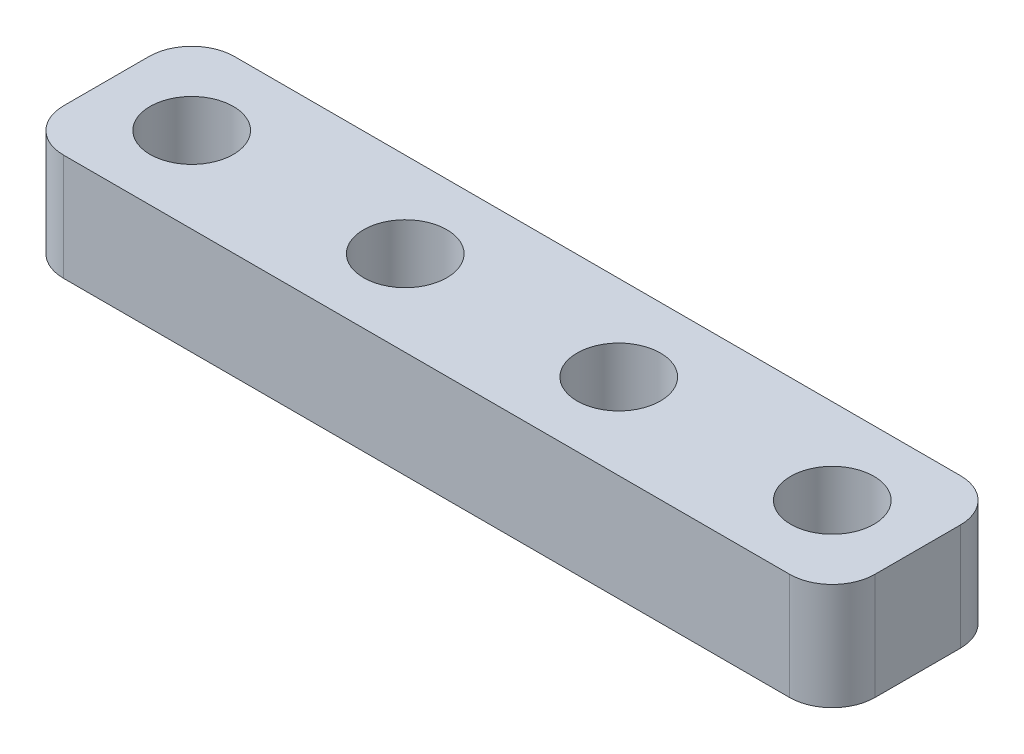
from build123d import *

# Parameters (mm, degrees)
BOSS_EXTRUDE1_DEPTH = 5
SKETCH2_R           = 1.95
CUT_EXTRUDE1_DEPTH  = 6


with BuildPart() as part:
    # Sketch1 → Boss-Extrude1 (new body)
    with BuildSketch(Plane(origin=(0, 0, 0), x_dir=(1, 0, 0), z_dir=(0, 1, 0))):
        with BuildLine():
            Line((2, 0), (36, 0))
            ThreePointArc((36, 0), (37.414213562, -0.585786438), (38, -2))
            Line((38, -2), (38, -6))
            ThreePointArc((38, -6), (37.414213562, -7.414213562), (36, -8))
            Line((36, -8), (2, -8))
            ThreePointArc((2, -8), (0.585786438, -7.414213562), (0, -6))
            Line((0, -6), (0, -2))
            ThreePointArc((0, -2), (0.585786438, -0.585786438), (2, 0))
        make_face()
    extrude(amount=BOSS_EXTRUDE1_DEPTH)

    # Sketch2 → Cut-Extrude1 (cut, through all)
    with BuildSketch(Plane(origin=(0, 5, 0), x_dir=(1, 0, 0), z_dir=(0, 1, 0))):
        with Locations((34, -4)):
            Circle(SKETCH2_R)
        with Locations((24, -4)):
            Circle(SKETCH2_R)
        with Locations((14, -4)):
            Circle(SKETCH2_R)
        with Locations((-16, -4)):
            Circle(SKETCH2_R)
        with Locations((4, -4)):
            Circle(SKETCH2_R)
        with Locations((-6, -4)):
            Circle(SKETCH2_R)
    extrude(amount=-CUT_EXTRUDE1_DEPTH, mode=Mode.SUBTRACT)


solid = part.part
